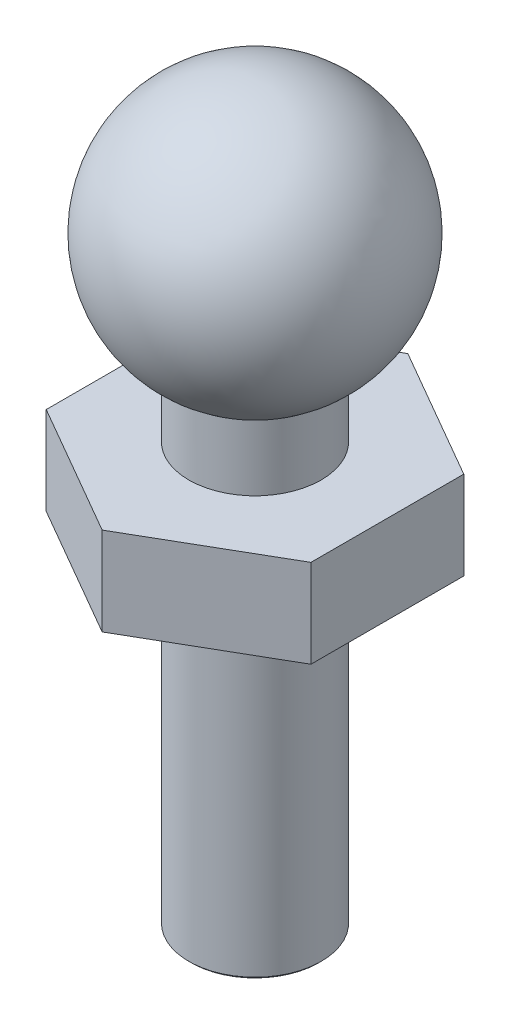
from build123d import *

# Parameters (mm, degrees)
CHAMFER1_SIZE       = 0.05
SKETCH3_R           = 1.5
BOSS_EXTRUDE1_DEPTH = 2


with BuildPart() as part:
    # Sketch1 → Revolve1 (revolve)
    with BuildSketch(Plane.XY):
        with BuildLine():
            Line((0, 0), (1.5, 0))
            Line((1.5, 0), (1.5, 11))
            ThreePointArc((1.5, 11), (2.897777479, 14.374533347), (0, 16.598076211))
            Line((0, 16.598076211), (0, 0))
        make_face()
    revolve(axis=Axis((0, 0, 0), (0, 1, 0)))

    # Chamfer1
    chamfer1_edges = [part.edges().sort_by_distance(p)[0] for p in [
        (-1.5, 0, 0),
    ]]
    chamfer(chamfer1_edges, length=CHAMFER1_SIZE)

    # Sketch3 → Boss-Extrude1 (add)
    with BuildSketch(Plane(origin=(0, 7.5, 0), x_dir=(1, 0, 0), z_dir=(0, 1, 0))):
        Polygon((3, 1.732050808), (0, 3.464101615), (-3, 1.732050808), (-3, -1.732050808), (0, -3.464101615), (3, -1.732050808), align=None)
        Circle(SKETCH3_R, mode=Mode.SUBTRACT)
    extrude(amount=BOSS_EXTRUDE1_DEPTH)


solid = part.part
